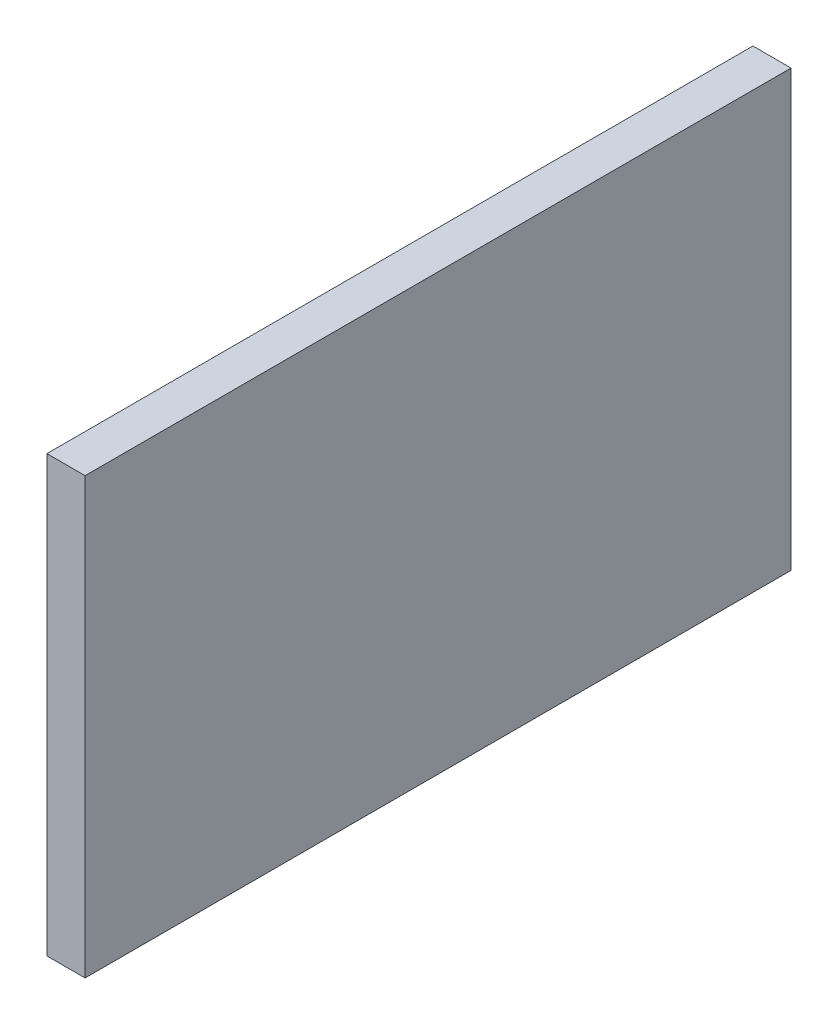
from build123d import *

# Parameters (mm, degrees)
SKETCH_1_W      = 185
SKETCH_1_H      = 114
EXTRUDE_1_DEPTH = 10


with BuildPart() as part:
    # 草图1 → 凸台-拉伸1 (new body)
    with BuildSketch(Plane(origin=(0, 0, 0), x_dir=(0, 0, -1), z_dir=(1, 0, 0))):
        Rectangle(SKETCH_1_W, SKETCH_1_H)
    extrude(amount=EXTRUDE_1_DEPTH)


solid = part.part
